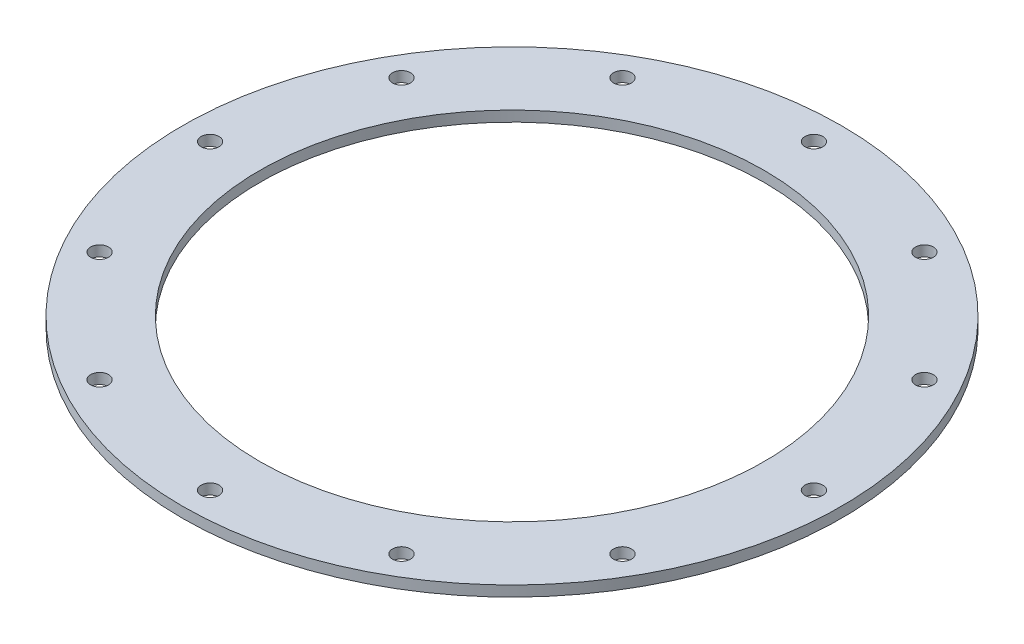
from build123d import *

# Parameters (mm, degrees)
SKETCH1_W                    = 11.684
SKETCH1_H                    = 1.5875
F_36_0_1065_DIAMETER_HOLE1_D = 2.7051
SCREW_PASSTHROUGHS_COUNT     = 12


with BuildPart() as part:
    # Sketch1 → Main (revolve)
    with BuildSketch(Plane.XY):
        with Locations((-43.942, 0.79375)):
            Rectangle(SKETCH1_W, SKETCH1_H)
    revolve(axis=Axis((0, 55, 0), (0, -1, 0)))

    # #36 (0.1065) Diameter Hole1 (through all)
    with Locations(Plane(origin=(0, 0, 0), x_dir=(-1, 0, 0), z_dir=(0, -1, 0))):
        with Locations((45.6057, 0)):
            f_36_0_1065_diameter_hole1 = Hole(F_36_0_1065_DIAMETER_HOLE1_D / 2)

    # Screw Passthroughs: #36 (0.1065) Diameter Hole1 ×12 about axis
    screw_passthroughs_axis = Axis((0, 0, 0), (0, 1, 0))
    for i in range(1, SCREW_PASSTHROUGHS_COUNT):
        add(f_36_0_1065_diameter_hole1.rotate(screw_passthroughs_axis, i * 360 / SCREW_PASSTHROUGHS_COUNT), mode=Mode.SUBTRACT)


solid = part.part
